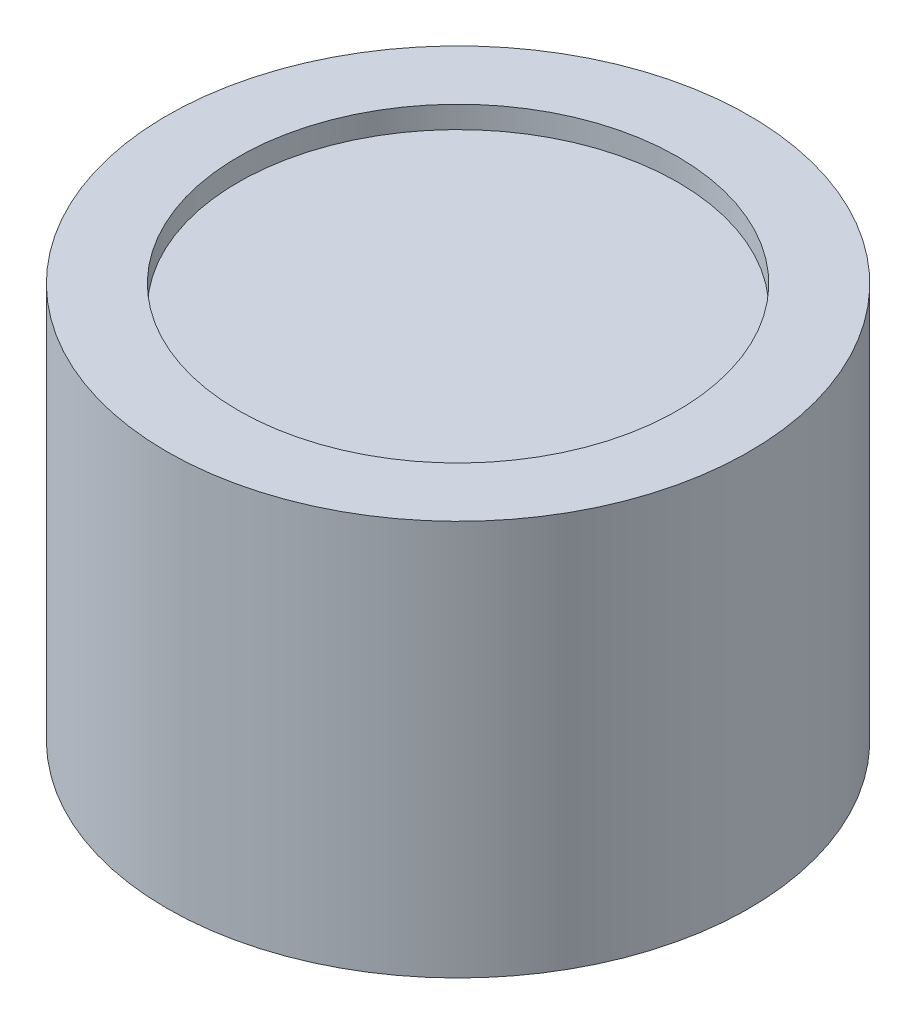
from build123d import *

# Parameters (mm, degrees)
SKETCH1_R           = 13.25
BOSS_EXTRUDE1_DEPTH = 35
SKETCH7_R           = 10
CUT_EXTRUDE4_DEPTH  = 8
SKETCH10_R          = 3.485
BOSS_EXTRUDE3_DEPTH = 4
CUT_EXTRUDE5_DEPTH  = 8.75
SKETCH13_R          = 10
CUT_EXTRUDE6_DEPTH  = 18
SKETCH14_R          = 13.25
CUT_EXTRUDE7_DEPTH  = 17


with BuildPart() as part:
    # Sketch1 → Boss-Extrude1 (new body)
    with BuildSketch(Plane(origin=(0, 0, 0), x_dir=(1, 0, 0), z_dir=(0, 1, 0))):
        Circle(SKETCH1_R)
    extrude(amount=BOSS_EXTRUDE1_DEPTH)

    # Sketch7 → Cut-Extrude4 (cut)
    with BuildSketch(Plane.XZ):
        Circle(SKETCH7_R)
    extrude(amount=-CUT_EXTRUDE4_DEPTH, mode=Mode.SUBTRACT)

    # Sketch10 → Boss-Extrude3 (add)
    with BuildSketch(Plane.XZ.offset(-8)):
        Circle(SKETCH10_R)
    extrude(amount=BOSS_EXTRUDE3_DEPTH)

    # Sketch11 → Cut-Extrude5 (cut)
    with BuildSketch(Plane.XZ.offset(-4)):
        with BuildLine():
            Line((1.123990489, -1.161812868), (-1.123990489, -1.161812868))
            ThreePointArc((-1.123990489, -1.161812868), (0, 1.616528304), (1.123990489, -1.161812868))
        make_face()
    extrude(amount=-CUT_EXTRUDE5_DEPTH, mode=Mode.SUBTRACT)

    # Sketch13 → Cut-Extrude6 (cut)
    with BuildSketch(Plane(origin=(0, 35, 0), x_dir=(1, 0, 0), z_dir=(0, 1, 0))):
        Circle(SKETCH13_R)
    extrude(amount=-CUT_EXTRUDE6_DEPTH, mode=Mode.SUBTRACT)

    # Sketch14 → Cut-Extrude7 (cut)
    with BuildSketch(Plane(origin=(0, 35, 0), x_dir=(1, 0, 0), z_dir=(0, 1, 0))):
        Circle(SKETCH14_R)
    extrude(amount=-CUT_EXTRUDE7_DEPTH, mode=Mode.SUBTRACT)


solid = part.part
